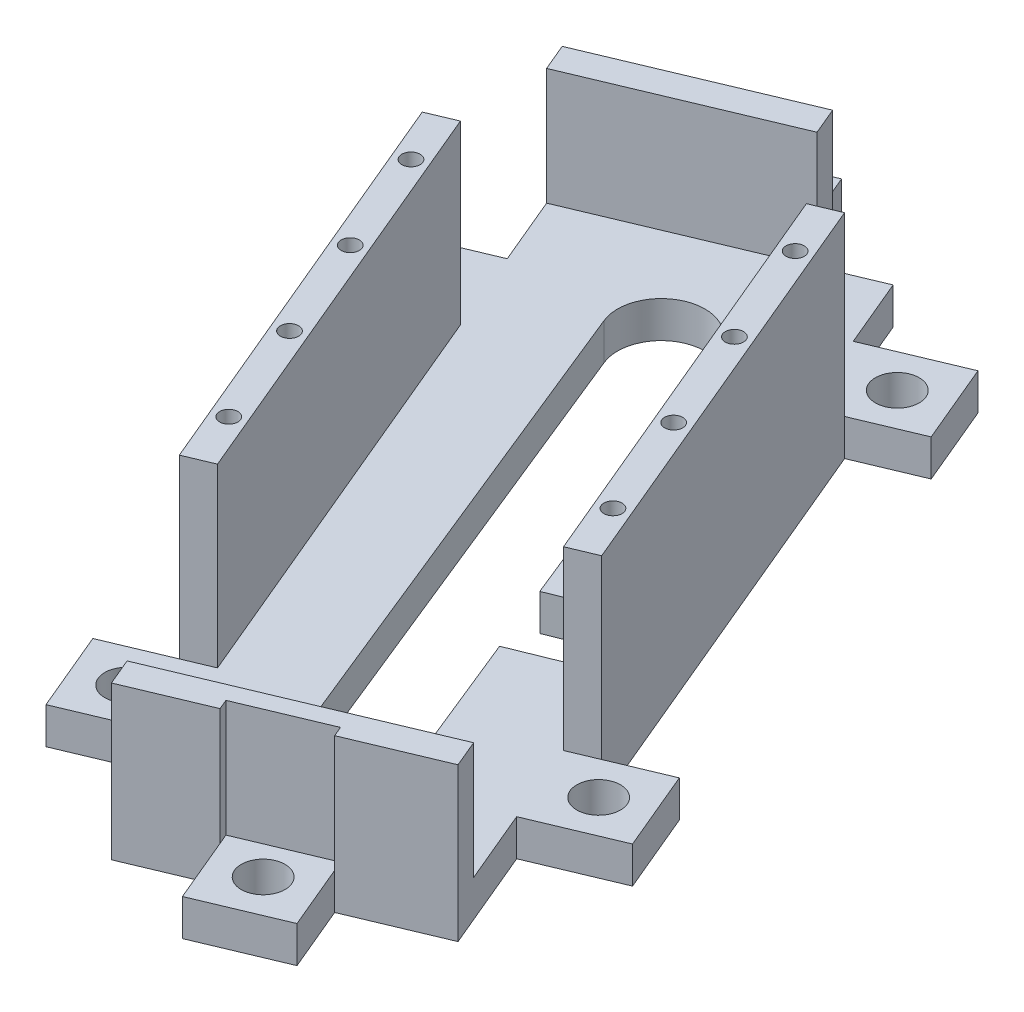
from build123d import *

# Parameters (mm, degrees)
CROQUIS1_R              = 3
SALIENTE_EXTRUIR1_DEPTH = 5
SALIENTE_EXTRUIR2_DEPTH = 16
SALIENTE_EXTRUIR3_DEPTH = 8.2
CROQUIS3_R              = 1.25
CORTAR_EXTRUIR1_DEPTH   = 5


with BuildPart() as part:
    # Croquis1 → Saliente-Extruir1 (new body)
    with BuildSketch(Plane(origin=(0, 308.658769599, 0), x_dir=(1, 0, 0), z_dir=(0, 1, 0))):
        Polygon((-79.783844322, -952.847201319), (-83.742628833, -943.41403856), (-91.093413893, -946.498918444), (-92.641298847, -942.810551303), (-95.774048426, -944.125262056), (-97.550477858, -939.892309261), (-99.87230529, -934.359758549), (-110.937406713, -939.003413413), (-106.839149849, -948.76891692), (-118.762445593, -953.772727382), (-117.214560638, -957.461094523), (-113.313042635, -966.757800174), (-118.964295032, -969.129442753), (-124.496845743, -971.451270185), (-119.85319088, -982.516371608), (-112.357754912, -979.370786552), (-88.272530549, -1036.762099686), (-91.095204728, -1037.946682112), (-96.62775544, -1040.268509543), (-91.984100576, -1051.333610967), (-79.940508545, -1046.279316155), (-75.615152484, -1056.58596144), (-74.067267529, -1060.274328581), (-63.576953324, -1055.871892786), (-59.845268011, -1064.763913767), (-48.780166587, -1060.120258903), (-51.101994019, -1054.587708191), (-52.511851901, -1051.228237922), (-40.595335724, -1046.227272618), (-42.143220678, -1042.538905477), (-46.411310232, -1032.3687173), (-40.753278269, -1029.994229562), (-35.220727557, -1027.67240213), (-39.864382421, -1016.607300707), (-47.366597955, -1019.755730922), (-71.451822317, -962.364417787), (-68.622368572, -961.176990204), (-63.089817861, -958.855162772), (-67.733472724, -947.790061349), align=None)
        with Locations((-88.773377296, -1043.479232823)):
            Circle(CROQUIS1_R, mode=Mode.SUBTRACT)
        with Locations((-56.634544731, -1056.909535623)):
            Circle(CROQUIS1_R, mode=Mode.SUBTRACT)
        with BuildLine():
            Line((-71.509217483, -1036.162059123), (-99.325497684, -967.476035253))
            ThreePointArc((-99.325497684, -967.476035253), (-96.112790855, -959.639858493), (-88.264495604, -962.822846557))
            ThreePointArc((-88.264495604, -962.822846557), (-88.224915609, -962.918213511), (-88.186982587, -963.014247451))
            Line((-88.186982587, -963.014247451), (-71.574392562, -1004.035287893))
            Line((-71.574392562, -1004.035287893), (-65.666191812, -1001.64260073))
            ThreePointArc((-65.666191812, -1001.64260073), (-62.233253946, -1001.525303468), (-59.534729647, -1003.650577014))
            ThreePointArc((-59.534729647, -1003.650577014), (-59.178911441, -1004.342131364), (-58.934639419, -1005.080497936))
            ThreePointArc((-58.934639419, -1005.080497936), (-59.336480357, -1008.551140269), (-61.912548923, -1010.911374385))
            Line((-61.912548923, -1010.911374385), (-67.820749673, -1013.304061547))
            Line((-67.820749673, -1013.304061547), (-60.387770455, -1031.658125581))
            ThreePointArc((-60.387770455, -1031.658125581), (-63.587576477, -1039.516957646), (-71.446408542, -1036.317151624))
            ThreePointArc((-71.446408542, -1036.317151624), (-71.478353691, -1036.239824336), (-71.509217483, -1036.162059123))
        make_face(mode=Mode.SUBTRACT)
        with Locations((-43.075105701, -1024.461678851)):
            Circle(CROQUIS1_R, mode=Mode.SUBTRACT)
        with Locations((-116.6424676, -974.661993465)):
            Circle(CROQUIS1_R, mode=Mode.SUBTRACT)
        with Locations((-103.08302857, -942.214136692)):
            Circle(CROQUIS1_R, mode=Mode.SUBTRACT)
        with Locations((-70.944196004, -955.644439492)):
            Circle(CROQUIS1_R, mode=Mode.SUBTRACT)
    extrude(amount=SALIENTE_EXTRUIR1_DEPTH)

    # Croquis2 → Saliente-Extruir2 (add)
    with BuildSketch(Plane(origin=(0, 313.658769599, 0), x_dir=(1, 0, 0), z_dir=(0, 1, 0))):
        Polygon((-112.357754912, -979.370786552), (-88.272530549, -1036.762099686), (-84.584163408, -1035.214214732), (-108.669387771, -977.822901597), align=None)
        Polygon((-71.451822317, -962.364417787), (-47.366597955, -1019.755730922), (-51.054965096, -1021.303615877), (-75.140189458, -963.912302742), align=None)
        Polygon((-91.093413893, -946.498918444), (-117.214560638, -957.461094523), (-118.762445593, -953.772727382), (-92.641298847, -942.810551303), align=None)
        Polygon((-74.067267529, -1060.274328581), (-63.576953324, -1055.871892786), (-64.157410182, -1054.488755108), (-53.092308759, -1049.845100244), (-52.511851901, -1051.228237922), (-40.595335724, -1046.227272618), (-42.143220678, -1042.538905477), (-75.615152484, -1056.58596144), align=None)
    extrude(amount=SALIENTE_EXTRUIR2_DEPTH)

    # Croquis4 → Saliente-Extruir3 (add)
    with BuildSketch(Plane(origin=(0, 329.658769599, 0), x_dir=(1, 0, 0), z_dir=(0, 1, 0))):
        Polygon((-112.357754912, -979.370786552), (-108.669387771, -977.822901597), (-84.584163408, -1035.214214732), (-88.272530549, -1036.762099686), align=None)
        Polygon((-75.140189458, -963.912302742), (-71.451822317, -962.364417787), (-47.366597955, -1019.755730922), (-51.054965096, -1021.303615877), align=None)
    extrude(amount=SALIENTE_EXTRUIR3_DEPTH)

    # Croquis3 → Cortar-Extruir1 (cut)
    with BuildSketch(Plane(origin=(0, 337.858769599, 0), x_dir=(1, 0, 0), z_dir=(0, 1, 0))):
        with Locations((-101.481612206, -1000.1185865)):
            Circle(CROQUIS3_R)
        with Locations((-107.502918296, -985.770758216)):
            Circle(CROQUIS3_R)
        with Locations((-95.460306115, -1014.466414784)):
            Circle(CROQUIS3_R)
        with Locations((-89.439000024, -1028.814243067)):
            Circle(CROQUIS3_R)
        with Locations((-70.285352842, -970.312274407)):
            Circle(CROQUIS3_R)
        with Locations((-64.264046752, -984.66010269)):
            Circle(CROQUIS3_R)
        with Locations((-52.22143457, -1013.355759258)):
            Circle(CROQUIS3_R)
        with Locations((-58.242740661, -999.007930974)):
            Circle(CROQUIS3_R)
    extrude(amount=-CORTAR_EXTRUIR1_DEPTH, mode=Mode.SUBTRACT)


solid = part.part
